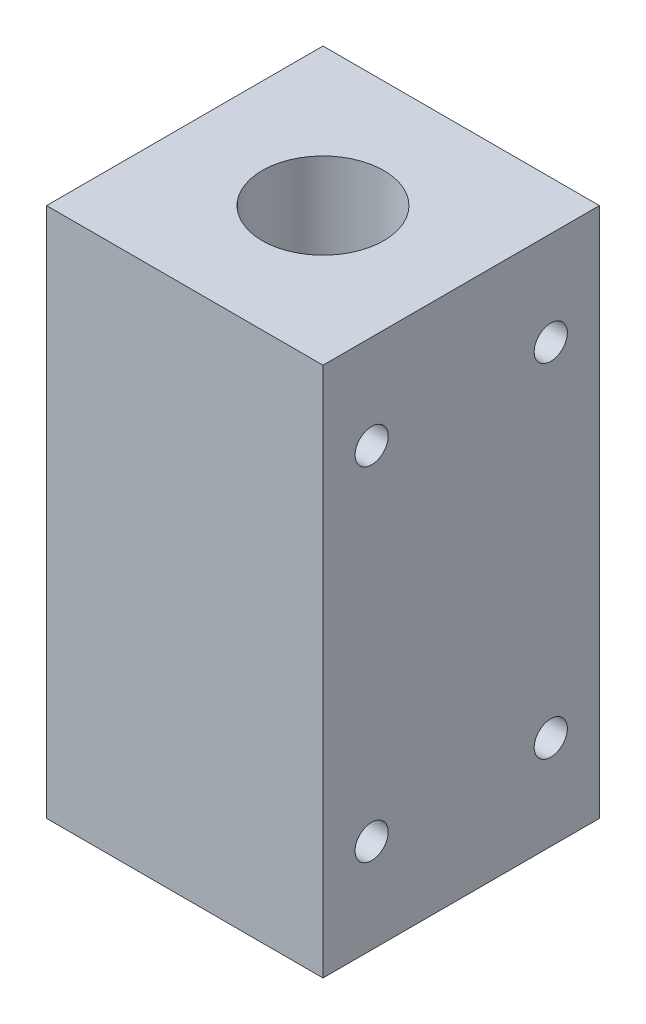
from build123d import *

# Parameters (mm, degrees)
SKETCH_1_W          = 25
SKETCH_1_H          = 25
SKETCH_1_R          = 5.5
EXTRUDE_1_DEPTH     = 48
SKETCH_2_R          = 1.5
CUT_EXTRUDE_1_DEPTH = 5


with BuildPart() as part:
    # 草图1 → 凸台-拉伸1 (new body)
    with BuildSketch(Plane(origin=(0, 0, 0), x_dir=(1, 0, 0), z_dir=(0, 1, 0))):
        Rectangle(SKETCH_1_W, SKETCH_1_H)
        Circle(SKETCH_1_R, mode=Mode.SUBTRACT)
    extrude(amount=EXTRUDE_1_DEPTH)

    # 草图2 → 切除-拉伸1 (cut)
    with BuildSketch(Plane(origin=(12.5, 0, 0), x_dir=(0, 0, -1), z_dir=(1, 0, 0))):
        with Locations((8.1, 8.5)):
            Circle(SKETCH_2_R)
        with Locations((-8.1, 8.5)):
            Circle(SKETCH_2_R)
        with Locations((-8.1, 39.5)):
            Circle(SKETCH_2_R)
        with Locations((8.1, 39.5)):
            Circle(SKETCH_2_R)
    extrude(amount=-CUT_EXTRUDE_1_DEPTH, mode=Mode.SUBTRACT)


solid = part.part
